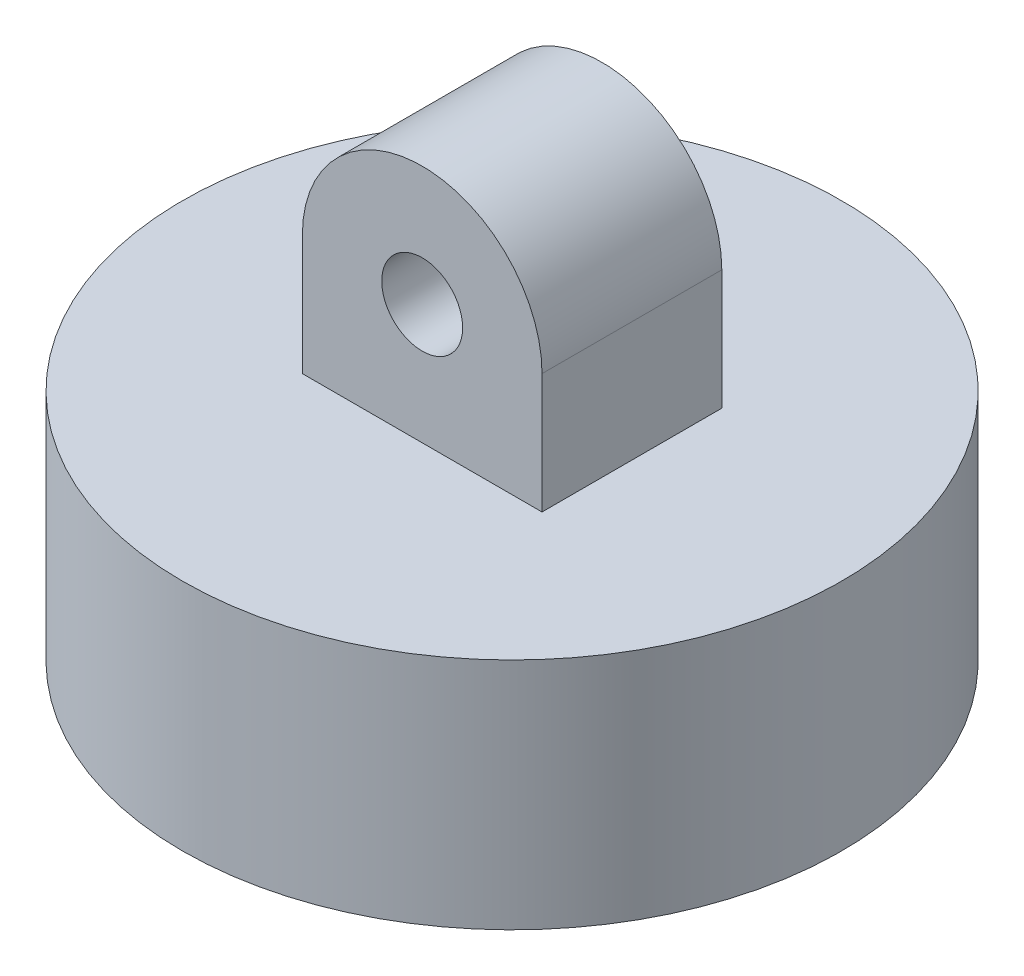
from build123d import *

# Parameters (mm, degrees)
SKETCH1_R           = 13.97
SKETCH1_R_2         = 8.89
BOSS_EXTRUDE1_DEPTH = 4.826
SKETCH2_R           = 13.97
BOSS_EXTRUDE2_DEPTH = 5.08
SKETCH3_R           = 1.7145
BOSS_EXTRUDE3_DEPTH = 3.81


with BuildPart() as part:
    # Sketch1 → Boss-Extrude1 (new body)
    with BuildSketch(Plane(origin=(0, 0, 0), x_dir=(1, 0, 0), z_dir=(0, 1, 0))):
        with Locations(Location((0, 0, 0), (0, 0, 270))):  # turned: the seam where the file's is
            Circle(SKETCH1_R)
        with Locations(Location((0, 0, 0), (0, 0, 270))):  # turned: the seam where the file's is
            Circle(SKETCH1_R_2, mode=Mode.SUBTRACT)
    extrude(amount=BOSS_EXTRUDE1_DEPTH)

    # Sketch2 → Boss-Extrude2 (add)
    with BuildSketch(Plane(origin=(0, 4.826, 0), x_dir=(1, 0, 0), z_dir=(0, 1, 0))):
        with Locations(Location((0, 0, 0), (0, 0, 270))):  # turned: the seam where the file's is
            Circle(SKETCH2_R)
    extrude(amount=BOSS_EXTRUDE2_DEPTH)

    # Sketch3 → Boss-Extrude3 (add, symmetric)
    with BuildSketch(Plane.XY):
        with BuildLine():
            Line((-5.08, 9.906), (-5.08, 14.986))
            ThreePointArc((-5.08, 14.986), (0, 20.066), (5.08, 14.986))
            Line((5.08, 14.986), (5.08, 9.906))
            Line((5.08, 9.906), (-5.08, 9.906))
        make_face()
        with Locations((0, 14.986)):
            Circle(SKETCH3_R, mode=Mode.SUBTRACT)
    extrude(amount=BOSS_EXTRUDE3_DEPTH, both=True)


solid = part.part
